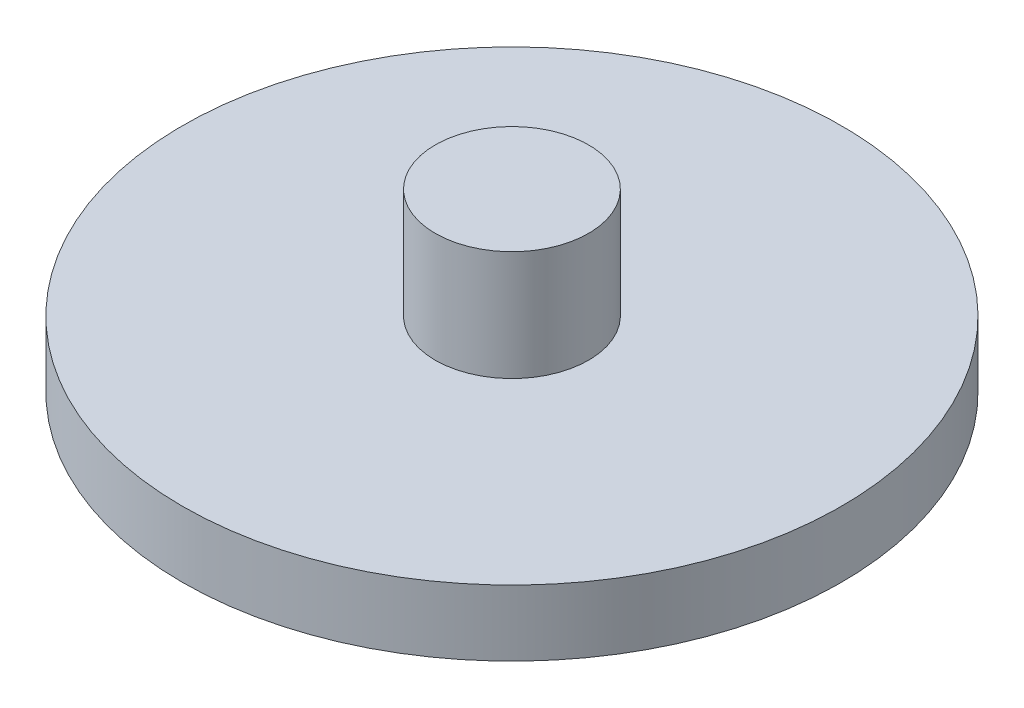
from build123d import *

# Parameters (mm, degrees)
SKETCH1_R           = 15
BOSS_EXTRUDE1_DEPTH = 3
SKETCH2_R           = 3.49
BOSS_EXTRUDE2_DEPTH = 5


with BuildPart() as part:
    # Sketch1 → Boss-Extrude1 (new body)
    with BuildSketch(Plane(origin=(0, 0, 0), x_dir=(1, 0, 0), z_dir=(0, 1, 0))):
        Circle(SKETCH1_R)
    extrude(amount=BOSS_EXTRUDE1_DEPTH)

    # Sketch2 → Boss-Extrude2 (add)
    with BuildSketch(Plane(origin=(0, 3, 0), x_dir=(1, 0, 0), z_dir=(0, 1, 0))):
        Circle(SKETCH2_R)
    extrude(amount=BOSS_EXTRUDE2_DEPTH)


solid = part.part
